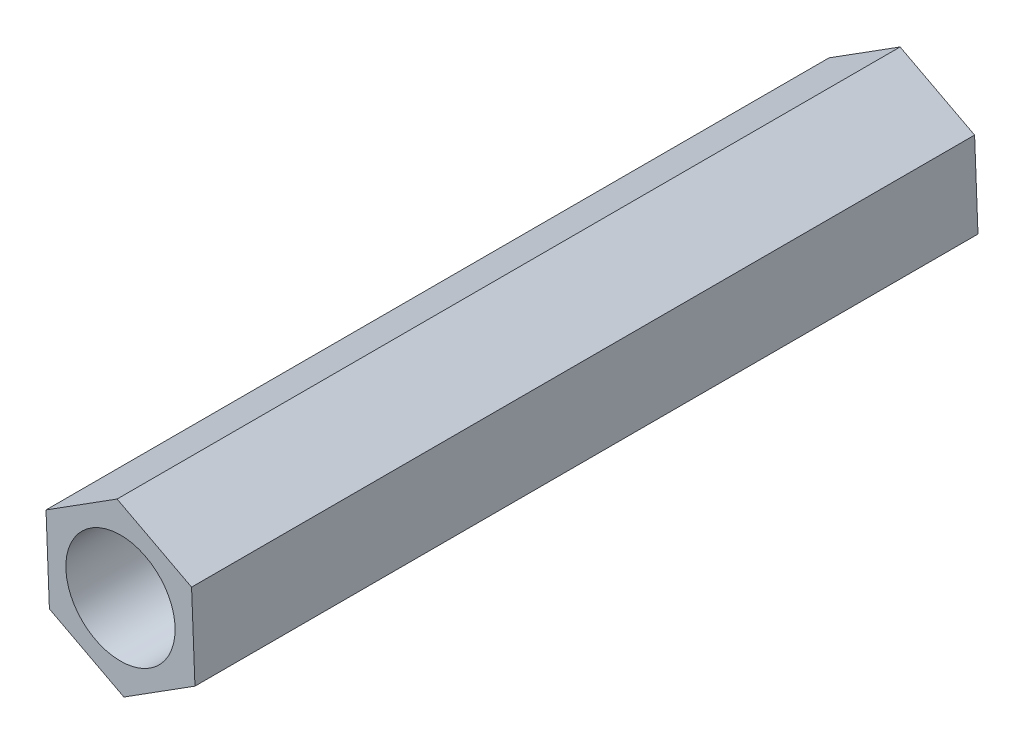
from build123d import *

# Parameters (mm, degrees)
EXTRUDE_1_DEPTH     = 43
CUT_EXTRUDE_1_REACH = 45
SKETCH_2_R          = 3


with BuildPart() as part:
    # 草图1 → 凸台-拉伸1 (new body)
    with BuildSketch(Plane.XY):
        Polygon((4.090282793, -2.145441681), (3.903148395, 2.469567967), (-0.187134399, 4.615009648), (-4.090282793, 2.145441681), (-3.903148395, -2.469567967), (0.187134399, -4.615009648), align=None)
    extrude(amount=EXTRUDE_1_DEPTH)

    # 草图2 → 切除-拉伸1 (cut, up to next)
    with BuildSketch(Plane.XY.offset(43), mode=Mode.PRIVATE) as cut_extrude_1_sk1:
        Circle(SKETCH_2_R)
    cut_extrude_1_tool1 = extrude(cut_extrude_1_sk1.sketch, amount=-CUT_EXTRUDE_1_REACH, mode=Mode.PRIVATE) & part.part
    add(cut_extrude_1_tool1.solids().sort_by_distance((0, 0, 43))[0], mode=Mode.SUBTRACT)


solid = part.part
